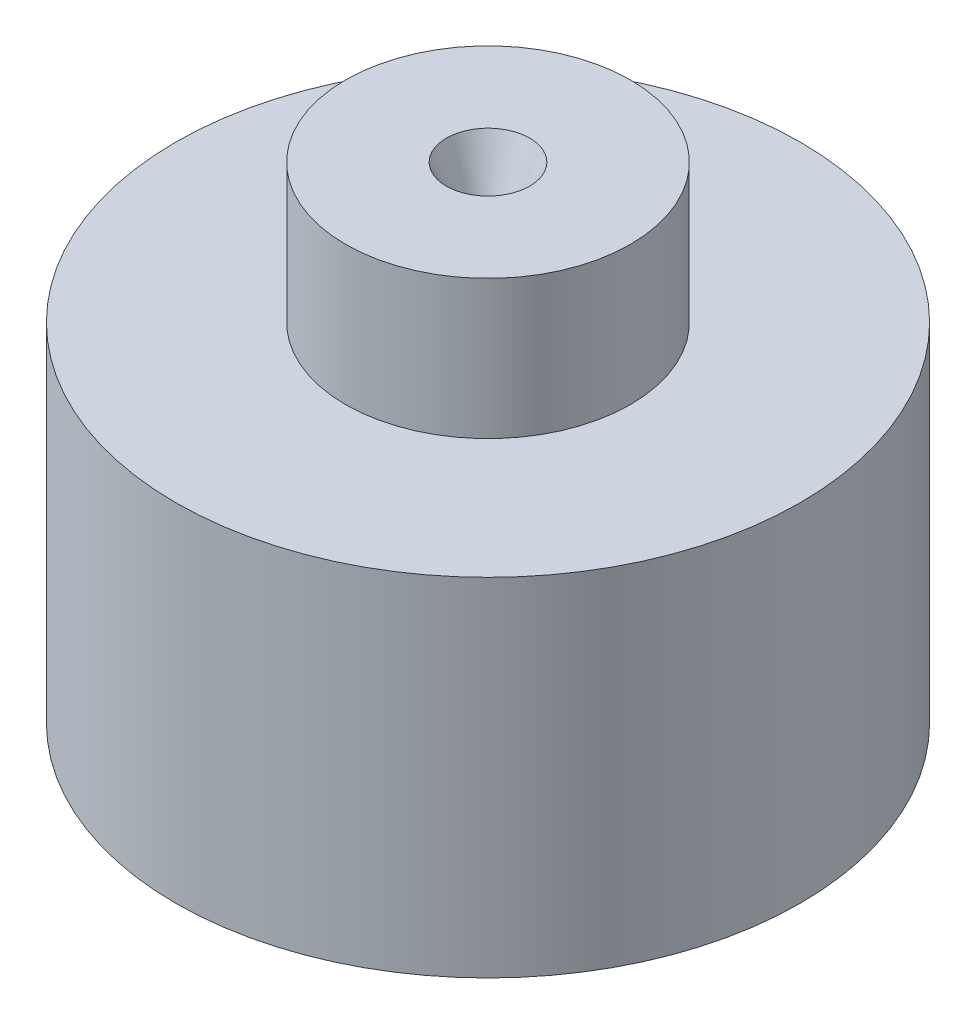
from build123d import *

# Parameters (mm, degrees)
SKETCH1_R           = 45
BOSS_EXTRUDE1_DEPTH = 50


with BuildPart() as part:
    # Sketch1 → Boss-Extrude1 (new body)
    with BuildSketch(Plane(origin=(0, 0, 0), x_dir=(1, 0, 0), z_dir=(0, 1, 0))):
        Circle(SKETCH1_R)
    extrude(amount=BOSS_EXTRUDE1_DEPTH)

    # Sketch2 → Cut-Revolve1 (revolve, cut)
    with BuildSketch(Plane(origin=(0, 0, 0), x_dir=(0, 0, -1), z_dir=(1, 0, 0))):
        Polygon((0, 50), (0, 0), (-40, 0), (-40, 10), (-37, 10), (-6, 41), (-6, 50), align=None)
    revolve(axis=Axis((0, 50, 0), (0, -1, 0)), mode=Mode.SUBTRACT)

    # Sketch3 → Revolve1 (revolve)
    with BuildSketch(Plane(origin=(0, 0, 0), x_dir=(0, 0, -1), z_dir=(1, 0, 0))):
        Polygon((-6, 50), (-20.522939955, 50), (-20.522939955, 70), (-6, 70), (-2.249869877, 61), (-2.249869877, 59), align=None)
    revolve(axis=Axis((0, 70, 0), (0, -1, 0)))


solid = part.part
